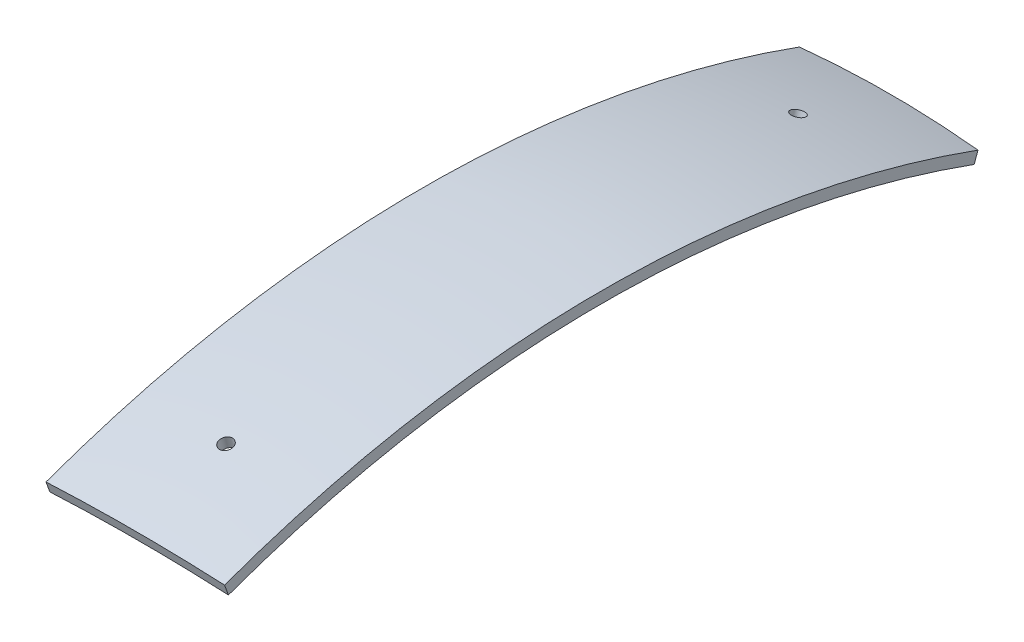
from build123d import *

# Parameters (mm, degrees)
REVOLVE1_ANGLE           = 20
REVOLVE1_OTHER_WAY_ANGLE = 20
SKETCH3_W                = 1.5
SKETCH3_H                = 54.140623468
CIRPATTERN2_COUNT        = 2


with BuildPart() as part:
    # Sketch1 → Revolve1 (revolve)
    with BuildSketch(Plane.XY):
        with BuildLine():
            ThreePointArc((-20, 244.182308941), (-10.008354244, 244.795491881), (0, 245))
            Line((0, 245), (0, 247.5))
            ThreePointArc((0, 247.5), (-10.008185841, 247.297566135), (-20, 246.690595686))
            Line((-20, 246.690595686), (-20, 244.182308941))
        make_face()
        with BuildLine():
            Line((0, 247.5), (0, 245))
            ThreePointArc((0, 245), (10.008354244, 244.795491881), (20, 244.182308941))
            Line((20, 244.182308941), (20, 246.690595686))
            ThreePointArc((20, 246.690595686), (10.008185841, 247.297566135), (0, 247.5))
        make_face()
    revolve(axis=Axis((-20, 0, 0), (1, 0, 0)), revolution_arc=REVOLVE1_ANGLE)

    # Sketch1 → Revolve1 other way (revolve)
    with BuildSketch(Plane.XY):
        with BuildLine():
            ThreePointArc((-20, 244.182308941), (-10.008354244, 244.795491881), (0, 245))
            Line((0, 245), (0, 247.5))
            ThreePointArc((0, 247.5), (-10.008185841, 247.297566135), (-20, 246.690595686))
            Line((-20, 246.690595686), (-20, 244.182308941))
        make_face()
        with BuildLine():
            Line((0, 247.5), (0, 245))
            ThreePointArc((0, 245), (10.008354244, 244.795491881), (20, 244.182308941))
            Line((20, 244.182308941), (20, 246.690595686))
            ThreePointArc((20, 246.690595686), (10.008185841, 247.297566135), (0, 247.5))
        make_face()
    revolve(axis=Axis((-20, 0, 0), (-1, 0, 0)), revolution_arc=REVOLVE1_OTHER_WAY_ANGLE)

    # Sketch3 → Cut-Revolve1 (revolve, cut)
    with BuildSketch(Plane(origin=(0, 0, 0), x_dir=(1, 0, 0), z_dir=(0, -0.258819045, 0.965925826))):
        with Locations((0.75, 245.792503526)):
            Rectangle(SKETCH3_W, SKETCH3_H)
    cut_revolve1 = revolve(axis=Axis((0, 0, 0), (0, 0.965925826, 0.258819045)), mode=Mode.SUBTRACT)

    # CirPattern2: Cut-Revolve1 ×2 about axis
    cirpattern2_axis = Axis((0, 0, 0), (0, 1, 0))
    for i in range(1, CIRPATTERN2_COUNT):
        add(cut_revolve1.rotate(cirpattern2_axis, i * 360 / CIRPATTERN2_COUNT), mode=Mode.SUBTRACT)


solid = part.part
